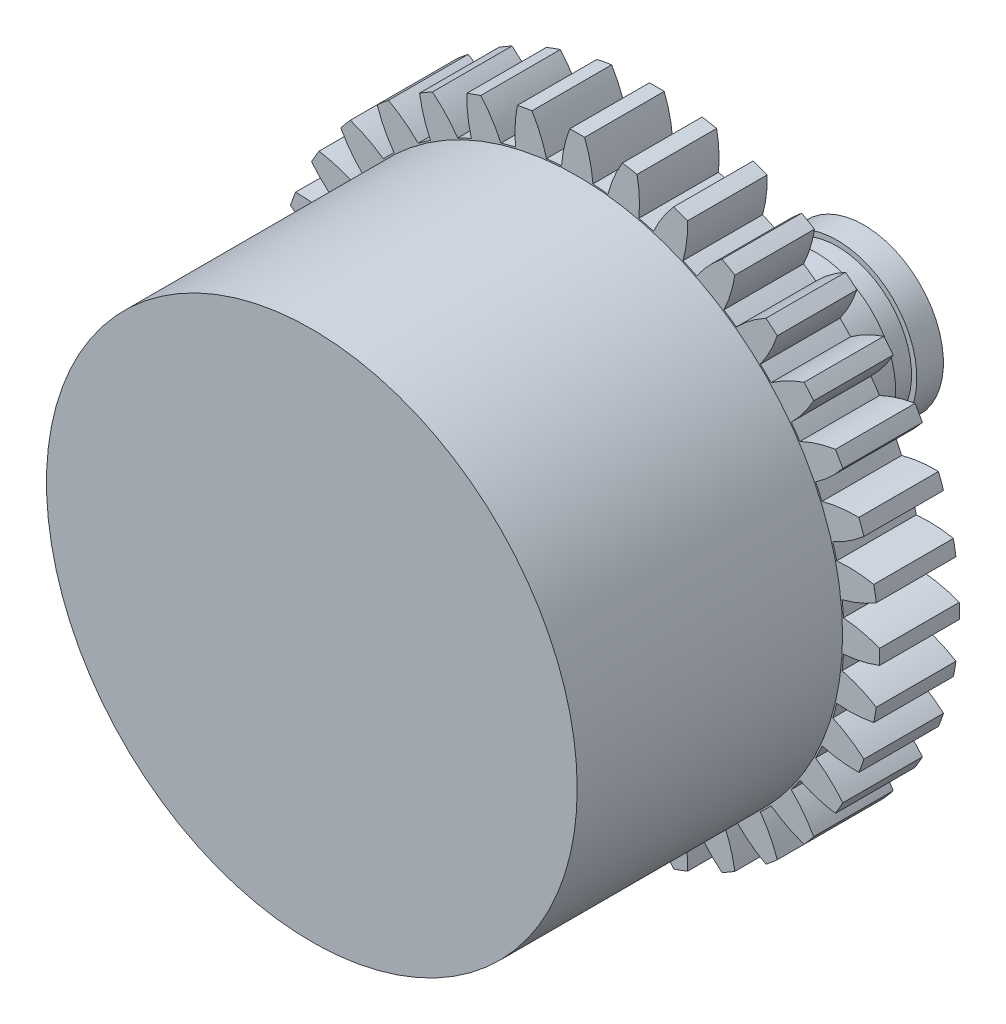
from build123d import *

# Parameters (mm, degrees)
SKETCH_1_R          = 5
EXTRUDE_1_DEPTH     = 5
SKETCH_2_R          = 1.5
EXTRUDE_2_DEPTH     = 5.4
SKETCH_3_R          = 2
EXTRUDE_3_DEPTH     = 2
SKETCH_4_R          = 0.79
CUT_EXTRUDE_1_DEPTH = 1.5
EXTRUDE_4_DEPTH     = 1.5
CUT_EXTRUDE_START   = 3
SKETCH_7_R          = 2
SKETCH_7_R_2        = 1.4
CUT_EXTRUDE_3_DEPTH = 0.4


with BuildPart() as part:
    # 스케치1 → 보스-돌출1 (new body)
    with BuildSketch(Plane.XY):
        Circle(SKETCH_1_R)
    extrude(amount=EXTRUDE_1_DEPTH)

    # 스케치2 → 보스-돌출2 (add)
    with BuildSketch(Plane(origin=(0, 0, 0), x_dir=(-1, 0, 0), z_dir=(0, 0, -1))):
        Circle(SKETCH_2_R)
    extrude(amount=EXTRUDE_2_DEPTH)

    # 스케치3 → 보스-돌출3 (add)
    with BuildSketch(Plane(origin=(0, 0, 0), x_dir=(-1, 0, 0), z_dir=(0, 0, -1))):
        Circle(SKETCH_3_R)
    extrude(amount=EXTRUDE_3_DEPTH)

    # 스케치4 → 컷-돌출1 (cut)
    with BuildSketch(Plane(origin=(0, 0, -5.4), x_dir=(-1, 0, 0), z_dir=(0, 0, -1))):
        Circle(SKETCH_4_R)
    extrude(amount=-CUT_EXTRUDE_1_DEPTH, mode=Mode.SUBTRACT)

    # 스케치5 → 보스-돌출4 (add)
    with BuildSketch(Plane(origin=(0, 0, 0), x_dir=(-1, 0, 0), z_dir=(0, 0, -1))):
        with BuildLine():
            ThreePointArc((-0.295754882, 5.016288872), (-0.243045211, 5.363052817), (-0.139875757, 5.698283494))
            ThreePointArc((-0.139875757, 5.698283494), (0, 5.7), (0.139875757, 5.698283494))
            ThreePointArc((0.139875757, 5.698283494), (0.243045211, 5.363052817), (0.295754882, 5.016288872))
            ThreePointArc((0.295754882, 5.016288872), (0.437957607, 5.005878358), (0.57980772, 4.991437469))
            ThreePointArc((0.57980772, 4.991437469), (0.69193154, 5.323780352), (0.851745815, 5.636002934))
            ThreePointArc((0.851745815, 5.636002934), (0.989794613, 5.613404192), (1.127247274, 5.587424593))
            ThreePointArc((1.127247274, 5.587424593), (1.170637157, 5.239371636), (1.162331123, 4.888722876))
            ThreePointArc((1.162331123, 4.888722876), (1.300565702, 4.853777277), (1.437753158, 4.814923764))
            ThreePointArc((1.437753158, 4.814923764), (1.605884302, 5.122747515), (1.817487521, 5.402475276))
            ThreePointArc((1.817487521, 5.402475276), (1.949514817, 5.356247938), (2.080367954, 5.306794624))
            ThreePointArc((2.080367954, 5.306794624), (2.062659884, 4.956494799), (1.99359052, 4.61261551))
            ThreePointArc((1.99359052, 4.61261551), (2.123656765, 4.55419663), (2.252013195, 4.492111037))
            ThreePointArc((2.252013195, 4.492111037), (2.471043081, 4.766062587), (2.728005788, 5.004796142))
            ThreePointArc((2.728005788, 5.004796142), (2.85, 4.936344802), (2.970277706, 4.864920385))
            ThreePointArc((2.970277706, 4.864920385), (2.892009736, 4.523017376), (2.764275678, 4.196356155))
            ThreePointArc((2.764275678, 4.196356155), (2.882221593, 4.116239023), (2.997846949, 4.03280779))
            ThreePointArc((2.997846949, 4.03280779), (3.261120467, 4.264563259), (3.55563498, 4.455048809))
            ThreePointArc((3.55563498, 4.455048809), (3.663889375, 4.366453326), (3.769937072, 4.275228002))
            ThreePointArc((3.769937072, 4.275228002), (3.633487334, 3.952110358), (3.450969718, 3.652592642))
            ThreePointArc((3.450969718, 3.652592642), (3.553211575, 3.553211575), (3.652592642, 3.450969718))
            ThreePointArc((3.652592642, 3.450969718), (3.952110358, 3.633487334), (4.275228002, 3.769937072))
            ThreePointArc((4.275228002, 3.769937072), (4.366453326, 3.663889375), (4.455048809, 3.55563498))
            ThreePointArc((4.455048809, 3.55563498), (4.264563259, 3.261120467), (4.03280779, 2.997846949))
            ThreePointArc((4.03280779, 2.997846949), (4.116239023, 2.882221593), (4.196356155, 2.764275678))
            ThreePointArc((4.196356155, 2.764275678), (4.523017376, 2.892009736), (4.864920385, 2.970277706))
            ThreePointArc((4.864920385, 2.970277706), (4.936344802, 2.85), (5.004796142, 2.728005788))
            ThreePointArc((5.004796142, 2.728005788), (4.766062587, 2.471043081), (4.492111037, 2.252013195))
            ThreePointArc((4.492111037, 2.252013195), (4.55419663, 2.123656765), (4.61261551, 1.99359052))
            ThreePointArc((4.61261551, 1.99359052), (4.956494799, 2.062659884), (5.306794624, 2.080367954))
            ThreePointArc((5.306794624, 2.080367954), (5.356247938, 1.949514817), (5.402475276, 1.817487521))
            ThreePointArc((5.402475276, 1.817487521), (5.122747515, 1.605884302), (4.814923764, 1.437753158))
            ThreePointArc((4.814923764, 1.437753158), (4.853777277, 1.300565702), (4.888722876, 1.162331123))
            ThreePointArc((4.888722876, 1.162331123), (5.239371636, 1.170637157), (5.587424593, 1.127247274))
            ThreePointArc((5.587424593, 1.127247274), (5.613404192, 0.989794613), (5.636002934, 0.851745815))
            ThreePointArc((5.636002934, 0.851745815), (5.323780352, 0.69193154), (4.991437469, 0.57980772))
            ThreePointArc((4.991437469, 0.57980772), (5.005878358, 0.437957607), (5.016288872, 0.295754882))
            ThreePointArc((5.016288872, 0.295754882), (5.363052817, 0.243045211), (5.698283494, 0.139875757))
            ThreePointArc((5.698283494, 0.139875757), (5.7, 0), (5.698283494, -0.139875757))
            ThreePointArc((5.698283494, -0.139875757), (5.363052817, -0.243045211), (5.016288872, -0.295754882))
            ThreePointArc((5.016288872, -0.295754882), (5.005878358, -0.437957607), (4.991437469, -0.57980772))
            ThreePointArc((4.991437469, -0.57980772), (5.323780352, -0.69193154), (5.636002934, -0.851745815))
            ThreePointArc((5.636002934, -0.851745815), (5.613404192, -0.989794613), (5.587424593, -1.127247274))
            ThreePointArc((5.587424593, -1.127247274), (5.239371636, -1.170637157), (4.888722876, -1.162331123))
            ThreePointArc((4.888722876, -1.162331123), (4.853777277, -1.300565702), (4.814923764, -1.437753158))
            ThreePointArc((4.814923764, -1.437753158), (5.122747515, -1.605884302), (5.402475276, -1.817487521))
            ThreePointArc((5.402475276, -1.817487521), (5.356247938, -1.949514817), (5.306794624, -2.080367954))
            ThreePointArc((5.306794624, -2.080367954), (4.956494799, -2.062659884), (4.61261551, -1.99359052))
            ThreePointArc((4.61261551, -1.99359052), (4.55419663, -2.123656765), (4.492111037, -2.252013195))
            ThreePointArc((4.492111037, -2.252013195), (4.766062587, -2.471043081), (5.004796142, -2.728005788))
            ThreePointArc((5.004796142, -2.728005788), (4.936344802, -2.85), (4.864920385, -2.970277706))
            ThreePointArc((4.864920385, -2.970277706), (4.523017376, -2.892009736), (4.196356155, -2.764275678))
            ThreePointArc((4.196356155, -2.764275678), (4.116239023, -2.882221593), (4.03280779, -2.997846949))
            ThreePointArc((4.03280779, -2.997846949), (4.264563259, -3.261120467), (4.455048809, -3.55563498))
            ThreePointArc((4.455048809, -3.55563498), (4.366453326, -3.663889375), (4.275228002, -3.769937072))
            ThreePointArc((4.275228002, -3.769937072), (3.952110358, -3.633487334), (3.652592642, -3.450969718))
            ThreePointArc((3.652592642, -3.450969718), (3.553211575, -3.553211575), (3.450969718, -3.652592642))
            ThreePointArc((3.450969718, -3.652592642), (3.633487334, -3.952110358), (3.769937072, -4.275228002))
            ThreePointArc((3.769937072, -4.275228002), (3.663889375, -4.366453326), (3.55563498, -4.455048809))
            ThreePointArc((3.55563498, -4.455048809), (3.261120467, -4.264563259), (2.997846949, -4.03280779))
            ThreePointArc((2.997846949, -4.03280779), (2.882221593, -4.116239023), (2.764275678, -4.196356155))
            ThreePointArc((2.764275678, -4.196356155), (2.892009736, -4.523017376), (2.970277706, -4.864920385))
            ThreePointArc((2.970277706, -4.864920385), (2.85, -4.936344802), (2.728005788, -5.004796142))
            ThreePointArc((2.728005788, -5.004796142), (2.471043081, -4.766062587), (2.252013195, -4.492111037))
            ThreePointArc((2.252013195, -4.492111037), (2.123656765, -4.55419663), (1.99359052, -4.61261551))
            ThreePointArc((1.99359052, -4.61261551), (2.062659884, -4.956494799), (2.080367954, -5.306794624))
            ThreePointArc((2.080367954, -5.306794624), (1.949514817, -5.356247938), (1.817487521, -5.402475276))
            ThreePointArc((1.817487521, -5.402475276), (1.605884302, -5.122747515), (1.437753158, -4.814923764))
            ThreePointArc((1.437753158, -4.814923764), (1.300565702, -4.853777277), (1.162331123, -4.888722876))
            ThreePointArc((1.162331123, -4.888722876), (1.170637157, -5.239371636), (1.127247274, -5.587424593))
            ThreePointArc((1.127247274, -5.587424593), (0.989794613, -5.613404192), (0.851745815, -5.636002934))
            ThreePointArc((0.851745815, -5.636002934), (0.69193154, -5.323780352), (0.57980772, -4.991437469))
            ThreePointArc((0.57980772, -4.991437469), (0.437957607, -5.005878358), (0.295754882, -5.016288872))
            ThreePointArc((0.295754882, -5.016288872), (0.243045211, -5.363052817), (0.139875757, -5.698283494))
            ThreePointArc((0.139875757, -5.698283494), (0, -5.7), (-0.139875757, -5.698283494))
            ThreePointArc((-0.139875757, -5.698283494), (-0.243045211, -5.363052817), (-0.295754882, -5.016288872))
            ThreePointArc((-0.295754882, -5.016288872), (-0.437957607, -5.005878358), (-0.57980772, -4.991437469))
            ThreePointArc((-0.57980772, -4.991437469), (-0.69193154, -5.323780352), (-0.851745815, -5.636002934))
            ThreePointArc((-0.851745815, -5.636002934), (-0.989794613, -5.613404192), (-1.127247274, -5.587424593))
            ThreePointArc((-1.127247274, -5.587424593), (-1.170637157, -5.239371636), (-1.162331123, -4.888722876))
            ThreePointArc((-1.162331123, -4.888722876), (-1.300565702, -4.853777277), (-1.437753158, -4.814923764))
            ThreePointArc((-1.437753158, -4.814923764), (-1.605884302, -5.122747515), (-1.817487521, -5.402475276))
            ThreePointArc((-1.817487521, -5.402475276), (-1.949514817, -5.356247938), (-2.080367954, -5.306794624))
            ThreePointArc((-2.080367954, -5.306794624), (-2.062659884, -4.956494799), (-1.99359052, -4.61261551))
            ThreePointArc((-1.99359052, -4.61261551), (-2.123656765, -4.55419663), (-2.252013195, -4.492111037))
            ThreePointArc((-2.252013195, -4.492111037), (-2.471043081, -4.766062587), (-2.728005788, -5.004796142))
            ThreePointArc((-2.728005788, -5.004796142), (-2.85, -4.936344802), (-2.970277706, -4.864920385))
            ThreePointArc((-2.970277706, -4.864920385), (-2.892009736, -4.523017376), (-2.764275678, -4.196356155))
            ThreePointArc((-2.764275678, -4.196356155), (-2.882221593, -4.116239023), (-2.997846949, -4.03280779))
            ThreePointArc((-2.997846949, -4.03280779), (-3.261120467, -4.264563259), (-3.55563498, -4.455048809))
            ThreePointArc((-3.55563498, -4.455048809), (-3.663889375, -4.366453326), (-3.769937072, -4.275228002))
            ThreePointArc((-3.769937072, -4.275228002), (-3.633487334, -3.952110358), (-3.450969718, -3.652592642))
            ThreePointArc((-3.450969718, -3.652592642), (-3.553211575, -3.553211575), (-3.652592642, -3.450969718))
            ThreePointArc((-3.652592642, -3.450969718), (-3.952110358, -3.633487334), (-4.275228002, -3.769937072))
            ThreePointArc((-4.275228002, -3.769937072), (-4.366453326, -3.663889375), (-4.455048809, -3.55563498))
            ThreePointArc((-4.455048809, -3.55563498), (-4.264563259, -3.261120467), (-4.03280779, -2.997846949))
            ThreePointArc((-4.03280779, -2.997846949), (-4.116239023, -2.882221593), (-4.196356155, -2.764275678))
            ThreePointArc((-4.196356155, -2.764275678), (-4.523017376, -2.892009736), (-4.864920385, -2.970277706))
            ThreePointArc((-4.864920385, -2.970277706), (-4.936344802, -2.85), (-5.004796142, -2.728005788))
            ThreePointArc((-5.004796142, -2.728005788), (-4.766062587, -2.471043081), (-4.492111037, -2.252013195))
            ThreePointArc((-4.492111037, -2.252013195), (-4.55419663, -2.123656765), (-4.61261551, -1.99359052))
            ThreePointArc((-4.61261551, -1.99359052), (-4.956494799, -2.062659884), (-5.306794624, -2.080367954))
            ThreePointArc((-5.306794624, -2.080367954), (-5.356247938, -1.949514817), (-5.402475276, -1.817487521))
            ThreePointArc((-5.402475276, -1.817487521), (-5.122747515, -1.605884302), (-4.814923764, -1.437753158))
            ThreePointArc((-4.814923764, -1.437753158), (-4.853777277, -1.300565702), (-4.888722876, -1.162331123))
            ThreePointArc((-4.888722876, -1.162331123), (-5.239371636, -1.170637157), (-5.587424593, -1.127247274))
            ThreePointArc((-5.587424593, -1.127247274), (-5.613404192, -0.989794613), (-5.636002934, -0.851745815))
            ThreePointArc((-5.636002934, -0.851745815), (-5.323780352, -0.69193154), (-4.991437469, -0.57980772))
            ThreePointArc((-4.991437469, -0.57980772), (-5.005878358, -0.437957607), (-5.016288872, -0.295754882))
            ThreePointArc((-5.016288872, -0.295754882), (-5.363052817, -0.243045211), (-5.698283494, -0.139875757))
            ThreePointArc((-5.698283494, -0.139875757), (-5.7, 0), (-5.698283494, 0.139875757))
            ThreePointArc((-5.698283494, 0.139875757), (-5.363052817, 0.243045211), (-5.016288872, 0.295754882))
            ThreePointArc((-5.016288872, 0.295754882), (-5.005878358, 0.437957607), (-4.991437469, 0.57980772))
            ThreePointArc((-4.991437469, 0.57980772), (-5.323780352, 0.69193154), (-5.636002934, 0.851745815))
            ThreePointArc((-5.636002934, 0.851745815), (-5.613404192, 0.989794613), (-5.587424593, 1.127247274))
            ThreePointArc((-5.587424593, 1.127247274), (-5.239371636, 1.170637157), (-4.888722876, 1.162331123))
            ThreePointArc((-4.888722876, 1.162331123), (-4.853777277, 1.300565702), (-4.814923764, 1.437753158))
            ThreePointArc((-4.814923764, 1.437753158), (-5.122747515, 1.605884302), (-5.402475276, 1.817487521))
            ThreePointArc((-5.402475276, 1.817487521), (-5.356247938, 1.949514817), (-5.306794624, 2.080367954))
            ThreePointArc((-5.306794624, 2.080367954), (-4.956494799, 2.062659884), (-4.61261551, 1.99359052))
            ThreePointArc((-4.61261551, 1.99359052), (-4.55419663, 2.123656765), (-4.492111037, 2.252013195))
            ThreePointArc((-4.492111037, 2.252013195), (-4.766062587, 2.471043081), (-5.004796142, 2.728005788))
            ThreePointArc((-5.004796142, 2.728005788), (-4.936344802, 2.85), (-4.864920385, 2.970277706))
            ThreePointArc((-4.864920385, 2.970277706), (-4.523017376, 2.892009736), (-4.196356155, 2.764275678))
            ThreePointArc((-4.196356155, 2.764275678), (-4.116239023, 2.882221593), (-4.03280779, 2.997846949))
            ThreePointArc((-4.03280779, 2.997846949), (-4.264563259, 3.261120467), (-4.455048809, 3.55563498))
            ThreePointArc((-4.455048809, 3.55563498), (-4.366453326, 3.663889375), (-4.275228002, 3.769937072))
            ThreePointArc((-4.275228002, 3.769937072), (-3.952110358, 3.633487334), (-3.652592642, 3.450969718))
            ThreePointArc((-3.652592642, 3.450969718), (-3.553211575, 3.553211575), (-3.450969718, 3.652592642))
            ThreePointArc((-3.450969718, 3.652592642), (-3.633487334, 3.952110358), (-3.769937072, 4.275228002))
            ThreePointArc((-3.769937072, 4.275228002), (-3.663889375, 4.366453326), (-3.55563498, 4.455048809))
            ThreePointArc((-3.55563498, 4.455048809), (-3.261120467, 4.264563259), (-2.997846949, 4.03280779))
            ThreePointArc((-2.997846949, 4.03280779), (-2.882221593, 4.116239023), (-2.764275678, 4.196356155))
            ThreePointArc((-2.764275678, 4.196356155), (-2.892009736, 4.523017376), (-2.970277706, 4.864920385))
            ThreePointArc((-2.970277706, 4.864920385), (-2.85, 4.936344802), (-2.728005788, 5.004796142))
            ThreePointArc((-2.728005788, 5.004796142), (-2.471043081, 4.766062587), (-2.252013195, 4.492111037))
            ThreePointArc((-2.252013195, 4.492111037), (-2.123656765, 4.55419663), (-1.99359052, 4.61261551))
            ThreePointArc((-1.99359052, 4.61261551), (-2.062659884, 4.956494799), (-2.080367954, 5.306794624))
            ThreePointArc((-2.080367954, 5.306794624), (-1.949514817, 5.356247938), (-1.817487521, 5.402475276))
            ThreePointArc((-1.817487521, 5.402475276), (-1.605884302, 5.122747515), (-1.437753158, 4.814923764))
            ThreePointArc((-1.437753158, 4.814923764), (-1.300565702, 4.853777277), (-1.162331123, 4.888722876))
            ThreePointArc((-1.162331123, 4.888722876), (-1.170637157, 5.239371636), (-1.127247274, 5.587424593))
            ThreePointArc((-1.127247274, 5.587424593), (-0.989794613, 5.613404192), (-0.851745815, 5.636002934))
            ThreePointArc((-0.851745815, 5.636002934), (-0.69193154, 5.323780352), (-0.57980772, 4.991437469))
            ThreePointArc((-0.57980772, 4.991437469), (-0.437957607, 5.005878358), (-0.295754882, 5.016288872))
        make_face()
    extrude(amount=EXTRUDE_4_DEPTH)

    # 스케치7 → 컷-돌출3 (cut)
    with BuildSketch(Plane(origin=(0, 0, -1.5), x_dir=(-1, 0, 0), z_dir=(0, 0, -1)).offset(CUT_EXTRUDE_START)):
        Circle(SKETCH_7_R)
        Circle(SKETCH_7_R_2, mode=Mode.SUBTRACT)
    extrude(amount=CUT_EXTRUDE_3_DEPTH, mode=Mode.SUBTRACT)


solid = part.part
